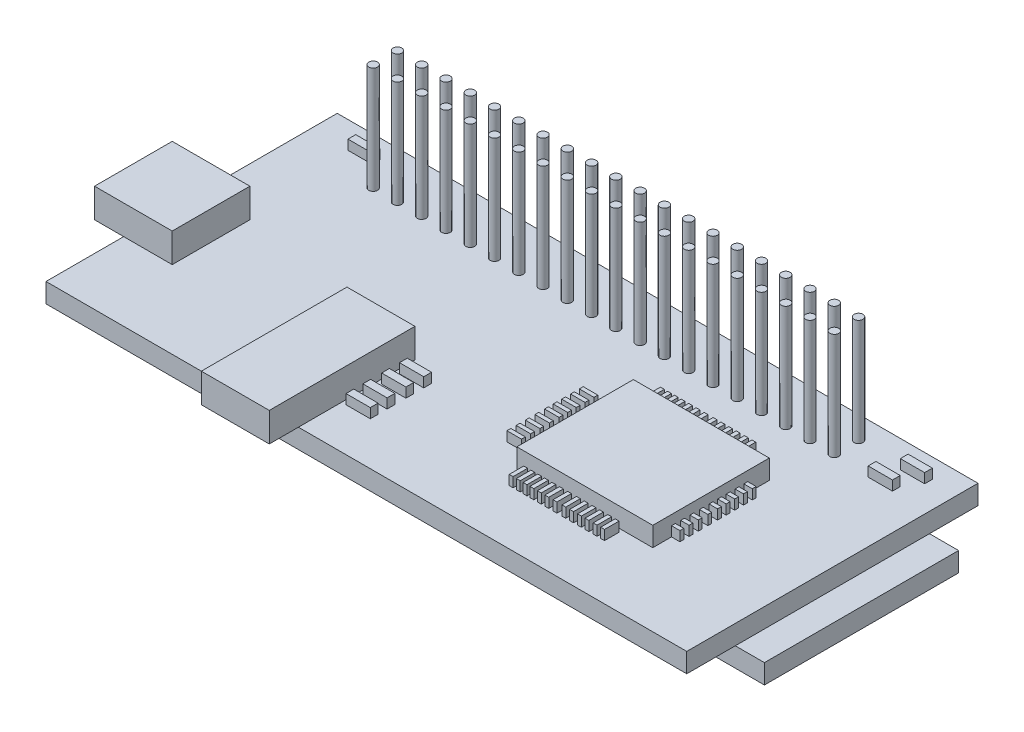
from build123d import *

# Parameters (mm, degrees)
SKETCH1_W            = 66
SKETCH1_H            = 30
BOSS_EXTRUDE1_DEPTH  = 2
SKETCH2_R            = 0.45
BOSS_EXTRUDE2_DEPTH  = 11
SKETCH3_W            = 2.5
SKETCH3_H            = 0.8
BOSS_EXTRUDE3_DEPTH  = 1
SKETCH4_W            = 7
SKETCH4_H            = 15
BOSS_EXTRUDE4_DEPTH  = 3
SKETCH6_W            = 8
SKETCH6_H            = 8
BOSS_EXTRUDE6_DEPTH  = 3
SKETCH7_W            = 14
SKETCH7_H            = 12
BOSS_EXTRUDE7_DEPTH  = 2
SKETCH9_W            = 1.5
SKETCH9_H            = 0.4
SKETCH9_W_2          = 0.4
SKETCH9_H_2          = 1.5
BOSS_EXTRUDE8_DEPTH  = 1
SKETCH10_W           = 6
SKETCH10_H           = 20
BOSS_EXTRUDE9_DEPTH  = 2
SKETCH11_W           = 51
SKETCH11_H           = 6.5
BOSS_EXTRUDE10_DEPTH = 11


with BuildPart() as part:
    # Sketch1 → Boss-Extrude1 (new body)
    with BuildSketch(Plane(origin=(0, 0, 0), x_dir=(1, 0, 0), z_dir=(0, 1, 0))):
        with Locations((33, 15)):
            Rectangle(SKETCH1_W, SKETCH1_H)
    extrude(amount=BOSS_EXTRUDE1_DEPTH)

    # Sketch2 → Boss-Extrude2 (add)
    with BuildSketch(Plane(origin=(0, 2, 0), x_dir=(1, 0, 0), z_dir=(0, 1, 0))):
        with Locations((8.5, 27.7)):
            Circle(SKETCH2_R)
        with Locations((8.5, 25.2)):
            Circle(SKETCH2_R)
        with Locations((11, 27.7)):
            Circle(SKETCH2_R)
        with Locations((11, 25.2)):
            Circle(SKETCH2_R)
        with Locations((13.5, 27.7)):
            Circle(SKETCH2_R)
        with Locations((13.5, 25.2)):
            Circle(SKETCH2_R)
        with Locations((16, 27.7)):
            Circle(SKETCH2_R)
        with Locations((16, 25.2)):
            Circle(SKETCH2_R)
        with Locations((18.5, 27.7)):
            Circle(SKETCH2_R)
        with Locations((18.5, 25.2)):
            Circle(SKETCH2_R)
        with Locations((21, 27.7)):
            Circle(SKETCH2_R)
        with Locations((21, 25.2)):
            Circle(SKETCH2_R)
        with Locations((23.5, 27.7)):
            Circle(SKETCH2_R)
        with Locations((23.5, 25.2)):
            Circle(SKETCH2_R)
        with Locations((26, 27.7)):
            Circle(SKETCH2_R)
        with Locations((26, 25.2)):
            Circle(SKETCH2_R)
        with Locations((28.5, 27.7)):
            Circle(SKETCH2_R)
        with Locations((28.5, 25.2)):
            Circle(SKETCH2_R)
        with Locations((31, 27.7)):
            Circle(SKETCH2_R)
        with Locations((31, 25.2)):
            Circle(SKETCH2_R)
        with Locations((33.5, 27.7)):
            Circle(SKETCH2_R)
        with Locations((33.5, 25.2)):
            Circle(SKETCH2_R)
        with Locations((36, 27.7)):
            Circle(SKETCH2_R)
        with Locations((36, 25.2)):
            Circle(SKETCH2_R)
        with Locations((38.5, 27.7)):
            Circle(SKETCH2_R)
        with Locations((38.5, 25.2)):
            Circle(SKETCH2_R)
        with Locations((41, 27.7)):
            Circle(SKETCH2_R)
        with Locations((41, 25.2)):
            Circle(SKETCH2_R)
        with Locations((43.5, 27.7)):
            Circle(SKETCH2_R)
        with Locations((43.5, 25.2)):
            Circle(SKETCH2_R)
        with Locations((46, 27.7)):
            Circle(SKETCH2_R)
        with Locations((46, 25.2)):
            Circle(SKETCH2_R)
        with Locations((48.5, 27.7)):
            Circle(SKETCH2_R)
        with Locations((48.5, 25.2)):
            Circle(SKETCH2_R)
        with Locations((51, 27.7)):
            Circle(SKETCH2_R)
        with Locations((51, 25.2)):
            Circle(SKETCH2_R)
        with Locations((53.5, 27.7)):
            Circle(SKETCH2_R)
        with Locations((53.5, 25.2)):
            Circle(SKETCH2_R)
        with Locations((56, 27.7)):
            Circle(SKETCH2_R)
        with Locations((56, 25.2)):
            Circle(SKETCH2_R)
    extrude(amount=BOSS_EXTRUDE2_DEPTH)

    # Sketch3 → Boss-Extrude3 (add)
    with BuildSketch(Plane(origin=(0, 2, 0), x_dir=(1, 0, 0), z_dir=(0, 1, 0))):
        with Locations((62.05, 27.6)):
            Rectangle(SKETCH3_W, SKETCH3_H)
        with Locations((61.05, 25.287931588)):
            Rectangle(SKETCH3_W, SKETCH3_H)
        with Locations((5.104597528, 27.65)):
            Rectangle(SKETCH3_W, SKETCH3_H)
        with Locations((27.7, 10.359652569)):
            Rectangle(SKETCH3_W, SKETCH3_H)
        with Locations((27.7, 8.523802555)):
            Rectangle(SKETCH3_W, SKETCH3_H)
        with Locations((27.7, 6.585960875)):
            Rectangle(SKETCH3_W, SKETCH3_H)
        with Locations((27.7, 4.852102529)):
            Rectangle(SKETCH3_W, SKETCH3_H)
    extrude(amount=BOSS_EXTRUDE3_DEPTH)

    # Sketch4 → Boss-Extrude4 (add)
    with BuildSketch(Plane(origin=(0, 2, 0), x_dir=(1, 0, 0), z_dir=(0, 1, 0))):
        with Locations((22.5, 4.5)):
            Rectangle(SKETCH4_W, SKETCH4_H)
    extrude(amount=BOSS_EXTRUDE4_DEPTH)

    # Sketch6 → Boss-Extrude6 (add)
    with BuildSketch(Plane(origin=(0, 2, 0), x_dir=(1, 0, 0), z_dir=(0, 1, 0))):
        with Locations((1, 12)):
            Rectangle(SKETCH6_W, SKETCH6_H)
    extrude(amount=BOSS_EXTRUDE6_DEPTH)

    # Sketch7 → Boss-Extrude7 (add)
    with BuildSketch(Plane(origin=(0, 2, 0), x_dir=(1, 0, 0), z_dir=(0, 1, 0))):
        with Locations((48, 13.5)):
            Rectangle(SKETCH7_W, SKETCH7_H)
    extrude(amount=BOSS_EXTRUDE7_DEPTH)

    # Sketch9 → Boss-Extrude8 (add)
    with BuildSketch(Plane(origin=(0, 2, 0), x_dir=(1, 0, 0), z_dir=(0, 1, 0))):
        with Locations((55.120202609, 13.5)):
            Rectangle(SKETCH9_W, SKETCH9_H)
        with Locations((55.120202609, 12.503384277)):
            Rectangle(SKETCH9_W, SKETCH9_H)
        with Locations((55.120202609, 11.516339652)):
            Rectangle(SKETCH9_W, SKETCH9_H)
        with Locations((55.120202609, 10.570736823)):
            Rectangle(SKETCH9_W, SKETCH9_H)
        with Locations((55.120202609, 9.625133994)):
            Rectangle(SKETCH9_W, SKETCH9_H)
        with Locations((55.120202609, 14.388170467)):
            Rectangle(SKETCH9_W, SKETCH9_H)
        with Locations((55.120202609, 15.263728642)):
            Rectangle(SKETCH9_W, SKETCH9_H)
        with Locations((55.120202609, 16.174309144)):
            Rectangle(SKETCH9_W, SKETCH9_H)
        with Locations((55.120202609, 17.084889646)):
            Rectangle(SKETCH9_W, SKETCH9_H)
        with Locations((38.802830433, 12.503384277)):
            Rectangle(SKETCH9_W, SKETCH9_H)
        with Locations((38.802830433, 14.388170467)):
            Rectangle(SKETCH9_W, SKETCH9_H)
        with Locations((38.802830433, 11.516339652)):
            Rectangle(SKETCH9_W, SKETCH9_H)
        with Locations((38.802830433, 15.263728642)):
            Rectangle(SKETCH9_W, SKETCH9_H)
        with Locations((38.802830433, 10.570736823)):
            Rectangle(SKETCH9_W, SKETCH9_H)
        with Locations((38.802830433, 16.174309144)):
            Rectangle(SKETCH9_W, SKETCH9_H)
        with Locations((46.78352382, 20.471698133)):
            Rectangle(SKETCH9_W_2, SKETCH9_H_2)
        with Locations((38.802830433, 13.5)):
            Rectangle(SKETCH9_W, SKETCH9_H)
        with Locations((38.802830433, 9.625133994)):
            Rectangle(SKETCH9_W, SKETCH9_H)
        with Locations((38.802830433, 17.084889646)):
            Rectangle(SKETCH9_W, SKETCH9_H)
        with Locations((47.694104322, 20.471698133)):
            Rectangle(SKETCH9_W_2, SKETCH9_H_2)
        with Locations((48.499617843, 20.471698133)):
            Rectangle(SKETCH9_W_2, SKETCH9_H_2)
        with Locations((49.305131364, 20.471698133)):
            Rectangle(SKETCH9_W_2, SKETCH9_H_2)
        with Locations((50.075622558, 20.471698133)):
            Rectangle(SKETCH9_W_2, SKETCH9_H_2)
        with Locations((50.916158406, 20.471698133)):
            Rectangle(SKETCH9_W_2, SKETCH9_H_2)
        with Locations((51.6866496, 20.471698133)):
            Rectangle(SKETCH9_W_2, SKETCH9_H_2)
        with Locations((45.942987972, 20.471698133)):
            Rectangle(SKETCH9_W_2, SKETCH9_H_2)
        with Locations((45.172496777, 20.471698133)):
            Rectangle(SKETCH9_W_2, SKETCH9_H_2)
        with Locations((44.402005583, 20.471698133)):
            Rectangle(SKETCH9_W_2, SKETCH9_H_2)
        with Locations((43.701559043, 20.471698133)):
            Rectangle(SKETCH9_W_2, SKETCH9_H_2)
        with Locations((43.001112503, 20.471698133)):
            Rectangle(SKETCH9_W_2, SKETCH9_H_2)
        with Locations((42.265643636, 20.471698133)):
            Rectangle(SKETCH9_W_2, SKETCH9_H_2)
        with Locations((51.6866496, 6.392722677)):
            Rectangle(SKETCH9_W_2, SKETCH9_H_2)
        with Locations((50.916158406, 6.392722677)):
            Rectangle(SKETCH9_W_2, SKETCH9_H_2)
        with Locations((50.075622558, 6.392722677)):
            Rectangle(SKETCH9_W_2, SKETCH9_H_2)
        with Locations((49.305131364, 6.392722677)):
            Rectangle(SKETCH9_W_2, SKETCH9_H_2)
        with Locations((48.499617843, 6.392722677)):
            Rectangle(SKETCH9_W_2, SKETCH9_H_2)
        with Locations((47.694104322, 6.392722677)):
            Rectangle(SKETCH9_W_2, SKETCH9_H_2)
        with Locations((46.78352382, 6.392722677)):
            Rectangle(SKETCH9_W_2, SKETCH9_H_2)
        with Locations((45.942987972, 6.392722677)):
            Rectangle(SKETCH9_W_2, SKETCH9_H_2)
        with Locations((45.172496777, 6.392722677)):
            Rectangle(SKETCH9_W_2, SKETCH9_H_2)
        with Locations((44.402005583, 6.392722677)):
            Rectangle(SKETCH9_W_2, SKETCH9_H_2)
        with Locations((43.701559043, 6.392722677)):
            Rectangle(SKETCH9_W_2, SKETCH9_H_2)
        with Locations((43.001112503, 6.392722677)):
            Rectangle(SKETCH9_W_2, SKETCH9_H_2)
        with Locations((42.265643636, 6.392722677)):
            Rectangle(SKETCH9_W_2, SKETCH9_H_2)
    extrude(amount=BOSS_EXTRUDE8_DEPTH)

    # Sketch10 → Boss-Extrude9 (add)
    with BuildSketch(Plane.XZ):
        with Locations((66, -15)):
            Rectangle(SKETCH10_W, SKETCH10_H)
    extrude(amount=BOSS_EXTRUDE9_DEPTH)

    # Sketch11 → Boss-Extrude10 (add)
    with BuildSketch(Plane.XZ):
        with Locations((32.5, -26.75)):
            Rectangle(SKETCH11_W, SKETCH11_H)
    extrude(amount=BOSS_EXTRUDE10_DEPTH)


solid = part.part
